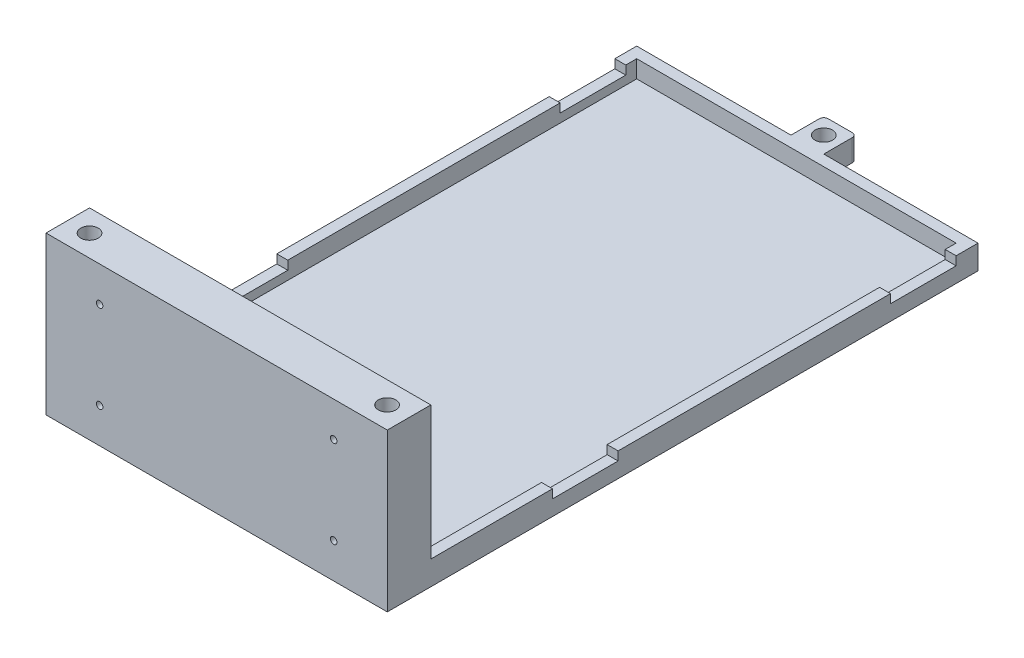
from build123d import *

# Parameters (mm, degrees)
BOSS_EXTRUDE1_DEPTH = 3
BOSS_EXTRUDE2_DEPTH = 8
BOSS_EXTRUDE3_DEPTH = 69
SKETCH4_R           = 4
CUT_EXTRUDE1_DEPTH  = 10
SKETCH5_W           = 5
SKETCH5_H           = 30
CUT_EXTRUDE2_DEPTH  = 4
SKETCH6_W           = 15
SKETCH6_H           = 15
BOSS_EXTRUDE4_DEPTH = 10
SKETCH7_R           = 4
CUT_EXTRUDE3_DEPTH  = 10
FILLET1_R           = 2
SKETCH8_R           = 1.5
CUT_EXTRUDE4_DEPTH  = 286


with BuildPart() as part:
    # Sketch1 → Boss-Extrude1 (new body)
    with BuildSketch(Plane(origin=(0, 0, 0), x_dir=(1, 0, 0), z_dir=(0, 1, 0))):
        Polygon((-78, -130), (-78, -140), (78, -140), (78, -130), (78, 130), (-78, 130), align=None)
    extrude(amount=BOSS_EXTRUDE1_DEPTH)

    # Sketch2 → Boss-Extrude2 (add)
    with BuildSketch(Plane(origin=(0, 3, 0), x_dir=(1, 0, 0), z_dir=(0, 1, 0))):
        Polygon((-73, -120.104101991), (-73, 125), (73, 125), (73, -120.104101991), (78, -120.104101991), (78, 130), (-78, 130), (-78, -120.104101991), align=None)
    extrude(amount=BOSS_EXTRUDE2_DEPTH)

    # Sketch3 → Boss-Extrude3 (add)
    with BuildSketch(Plane(origin=(0, 3, 0), x_dir=(1, 0, 0), z_dir=(0, 1, 0))):
        Polygon((73, -120.104101991), (78, -120.104101991), (78, -140), (-78, -140), (-78, -120.104101991), (-73, -120.104101991), align=None)
    extrude(amount=BOSS_EXTRUDE3_DEPTH)

    # Sketch4 → Cut-Extrude1 (cut)
    with BuildSketch(Plane(origin=(0, 72, 0), x_dir=(1, 0, 0), z_dir=(0, 1, 0))):
        with Locations((-68, -130.104101991)):
            Circle(SKETCH4_R)
        with Locations((68, -130.104101991)):
            Circle(SKETCH4_R)
    extrude(amount=-CUT_EXTRUDE1_DEPTH, mode=Mode.SUBTRACT)

    # Sketch5 → Cut-Extrude2 (cut)
    with BuildSketch(Plane(origin=(0, 11, 0), x_dir=(1, 0, 0), z_dir=(0, 1, 0))):
        with Locations((-75.5, 105)):
            Rectangle(SKETCH5_W, SKETCH5_H)
        with Locations((-75.5, -49.5)):
            Rectangle(SKETCH5_W, SKETCH5_H)
        with Locations((75.5, -49.5)):
            Rectangle(SKETCH5_W, SKETCH5_H)
        with Locations((75.5, 105)):
            Rectangle(SKETCH5_W, SKETCH5_H)
    extrude(amount=-CUT_EXTRUDE2_DEPTH, mode=Mode.SUBTRACT)

    # Sketch6 → Boss-Extrude4 (add)
    with BuildSketch(Plane(origin=(0, 11, 0), x_dir=(1, 0, 0), z_dir=(0, 1, 0))):
        with Locations((0, 137.5)):
            Rectangle(SKETCH6_W, SKETCH6_H)
    extrude(amount=-BOSS_EXTRUDE4_DEPTH)

    # Sketch7 → Cut-Extrude3 (cut)
    with BuildSketch(Plane(origin=(0, 11, 0), x_dir=(1, 0, 0), z_dir=(0, 1, 0))):
        with Locations((0, 137.5)):
            Circle(SKETCH7_R)
    extrude(amount=-CUT_EXTRUDE3_DEPTH, mode=Mode.SUBTRACT)

    # Fillet1
    fillet1_edges = [part.edges().sort_by_distance(p)[0] for p in [
        (7.5, 6, -145),
        (-7.5, 6, -145),
    ]]
    fillet(fillet1_edges, radius=FILLET1_R)

    # Sketch8 → Cut-Extrude4 (cut, through all)
    with BuildSketch(Plane.XY.offset(140)):
        with Locations((53.5, 56)):
            Circle(SKETCH8_R)
        with Locations((53.5, 16)):
            Circle(SKETCH8_R)
        with Locations((-53.5, 16)):
            Circle(SKETCH8_R)
        with Locations((-53.5, 56)):
            Circle(SKETCH8_R)
    extrude(amount=-CUT_EXTRUDE4_DEPTH, mode=Mode.SUBTRACT)


solid = part.part
